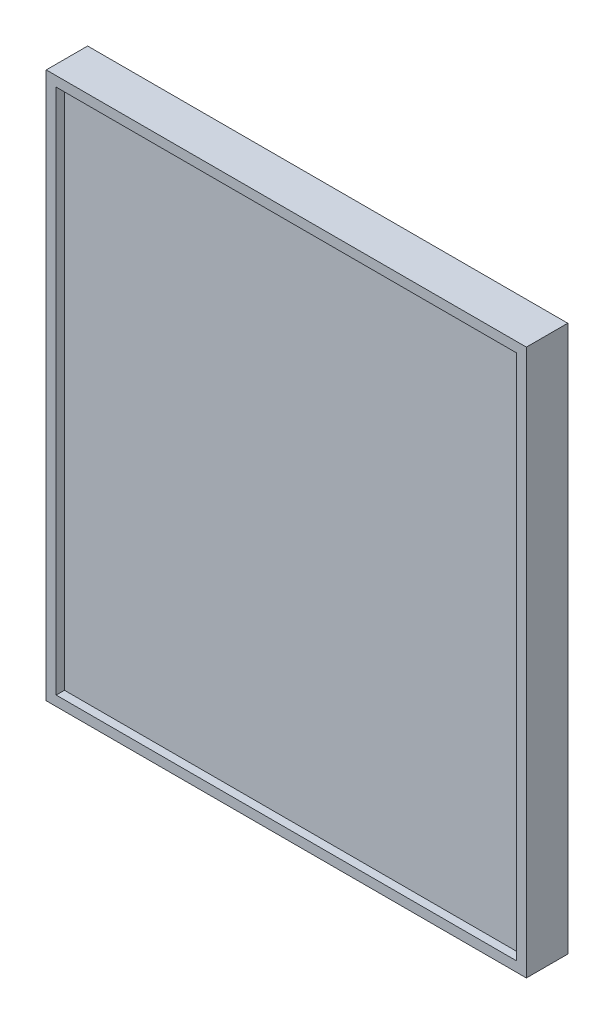
from build123d import *

# Parameters (mm, degrees)
SKETCH1_W           = 290
SKETCH1_H           = 330
BOSS_EXTRUDE2_DEPTH = 25
SKETCH7_W           = 278
SKETCH7_H           = 318
CUT_EXTRUDE3_DEPTH  = 5


with BuildPart() as part:
    # Sketch1 → Boss-Extrude2 (new body)
    with BuildSketch(Plane.XY):
        Rectangle(SKETCH1_W, SKETCH1_H)
    extrude(amount=BOSS_EXTRUDE2_DEPTH)

    # Sketch7 → Cut-Extrude3 (cut)
    with BuildSketch(Plane.XY.offset(25)):
        Rectangle(SKETCH7_W, SKETCH7_H)
    extrude(amount=-CUT_EXTRUDE3_DEPTH, mode=Mode.SUBTRACT)


solid = part.part
